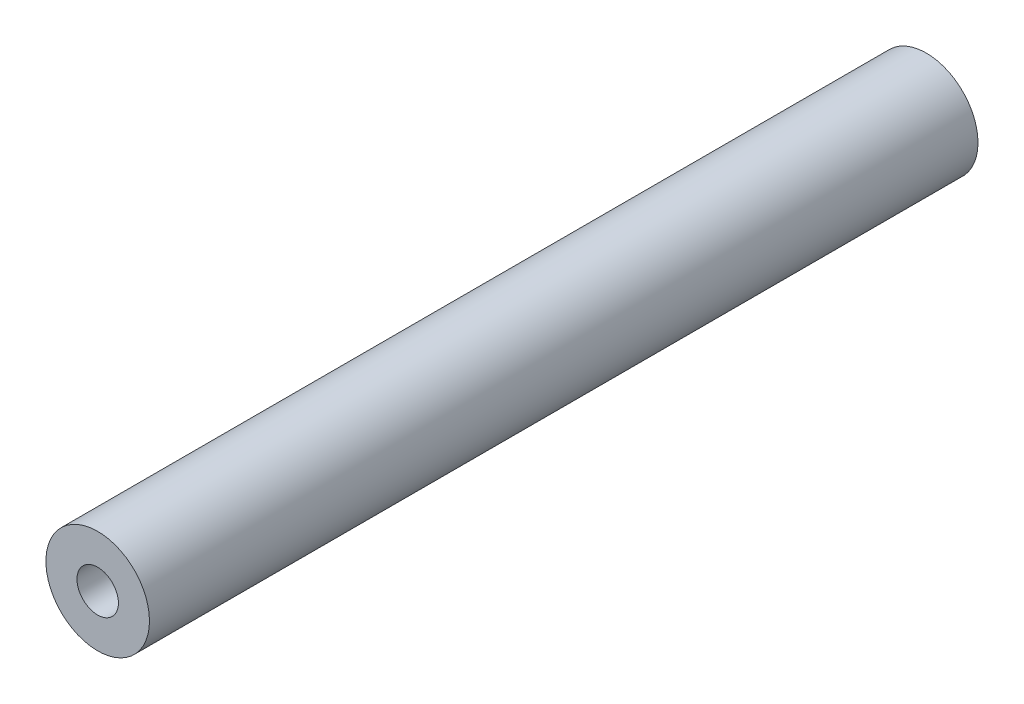
from build123d import *

# Parameters (mm, degrees)
CROQUIS1_R              = 25
CROQUIS1_R_2            = 10
SALIENTE_EXTRUIR1_DEPTH = 400


with BuildPart() as part:
    # Croquis1 → Saliente-Extruir1 (new body)
    with BuildSketch(Plane.XY):
        Circle(CROQUIS1_R)
        Circle(CROQUIS1_R_2, mode=Mode.SUBTRACT)
    extrude(amount=SALIENTE_EXTRUIR1_DEPTH)


solid = part.part
